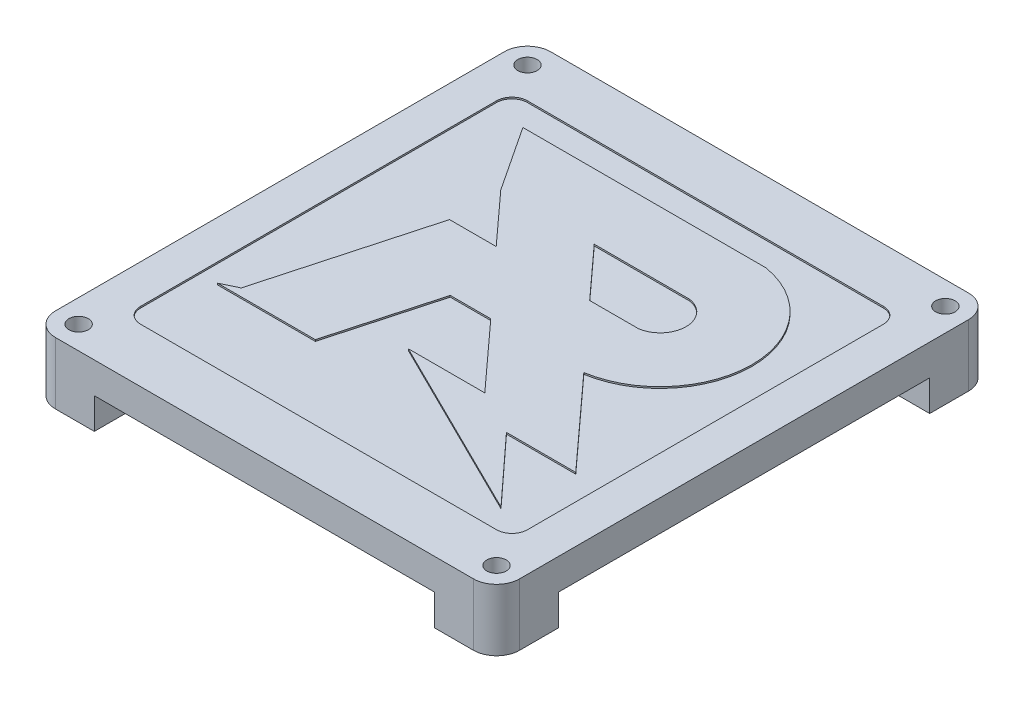
from build123d import *

# Parameters (mm, degrees)
EXTRUDE_1_DEPTH     = 4
EXTRUDE_2_DEPTH     = 4
SKETCH_3_R          = 1.25
CUT_EXTRUDE_1_DEPTH = 15
CUT_EXTRUDE_2_DEPTH = 0.2


with BuildPart() as part:
    # 草图1 → 凸台-拉伸1 (new body)
    with BuildSketch(Plane(origin=(0, 0, 0), x_dir=(1, 0, 0), z_dir=(0, 1, 0))):
        with BuildLine():
            Line((-27.00005461, -31.987363475), (27.00005461, -31.987363475))
            ThreePointArc((27.00005461, -31.987363475), (29.112398272, -31.112402082), (29.987359665, -29.00005842))
            Line((29.987359665, -29.00005842), (29.987359665, 29.00005842))
            ThreePointArc((29.987359665, 29.00005842), (29.112398272, 31.112402082), (27.00005461, 31.987363475))
            Line((27.00005461, 31.987363475), (-27.00005461, 31.987363475))
            ThreePointArc((-27.00005461, 31.987363475), (-29.112398272, 31.112402082), (-29.987359665, 29.00005842))
            Line((-29.987359665, 29.00005842), (-29.987359665, -29.00005842))
            ThreePointArc((-29.987359665, -29.00005842), (-29.112398272, -31.112402082), (-27.00005461, -31.987363475))
        make_face()
    extrude(amount=EXTRUDE_1_DEPTH)

    # 草图2 → 凸台-拉伸2 (add)
    with BuildSketch(Plane.XZ):
        with BuildLine():
            Line((21.987359665, 23.987363475), (29.987359665, 23.987363475))
            Line((29.987359665, 23.987363475), (29.987359665, 29.00005842))
            ThreePointArc((29.987359665, 29.00005842), (29.112398272, 31.112402082), (27.00005461, 31.987363475))
            Line((27.00005461, 31.987363475), (21.987359665, 31.987363475))
            Line((21.987359665, 31.987363475), (21.987359665, 23.987363475))
        make_face()
        with BuildLine():
            Line((27.00005461, -31.987363475), (21.987359665, -31.987363475))
            Line((21.987359665, -31.987363475), (21.987359665, -23.987363475))
            Line((21.987359665, -23.987363475), (29.987359665, -23.987363475))
            Line((29.987359665, -23.987363475), (29.987359665, -29.00005842))
            ThreePointArc((29.987359665, -29.00005842), (29.112398272, -31.112402082), (27.00005461, -31.987363475))
        make_face()
        with BuildLine():
            Line((-21.987359665, 23.987363475), (-21.987359665, 31.987363475))
            Line((-21.987359665, 31.987363475), (-27.00005461, 31.987363475))
            ThreePointArc((-27.00005461, 31.987363475), (-29.112398272, 31.112402082), (-29.987359665, 29.00005842))
            Line((-29.987359665, 29.00005842), (-29.987359665, 23.987363475))
            Line((-29.987359665, 23.987363475), (-21.987359665, 23.987363475))
        make_face()
        with BuildLine():
            Line((-29.987359665, -23.987363475), (-29.987359665, -29.00005842))
            ThreePointArc((-29.987359665, -29.00005842), (-29.112398272, -31.112402082), (-27.00005461, -31.987363475))
            Line((-27.00005461, -31.987363475), (-21.987359665, -31.987363475))
            Line((-21.987359665, -31.987363475), (-21.987359665, -23.987363475))
            Line((-21.987359665, -23.987363475), (-29.987359665, -23.987363475))
        make_face()
    extrude(amount=EXTRUDE_2_DEPTH)

    # 草图3 → 切除-拉伸1 (cut)
    with BuildSketch(Plane.XZ.offset(4)):
        with Locations((-27.00005461, 29.00005842)):
            Circle(SKETCH_3_R)
        with Locations((27.00005461, 29.00005842)):
            Circle(SKETCH_3_R)
        with Locations((27.00005461, -29.00005842)):
            Circle(SKETCH_3_R)
        with Locations((-27.00005461, -29.00005842)):
            Circle(SKETCH_3_R)
    extrude(amount=-CUT_EXTRUDE_1_DEPTH, mode=Mode.SUBTRACT)

    # 草图5 → 切除-拉伸2 (cut)
    with BuildSketch(Plane(origin=(0, 4, 0), x_dir=(1, 0, 0), z_dir=(0, 1, 0))):
        with BuildLine():
            Line((-23, 25), (23, 25))
            ThreePointArc((23, 25), (24.414213562, 24.414213562), (25, 23))
            Line((25, 23), (25, -23))
            ThreePointArc((25, -23), (24.414213562, -24.414213562), (23, -25))
            Line((23, -25), (-23, -25))
            ThreePointArc((-23, -25), (-24.414213562, -24.414213562), (-25, -23))
            Line((-25, -23), (-25, 23))
            ThreePointArc((-25, 23), (-24.414213562, 24.414213562), (-23, 25))
        make_face()
        with BuildLine():
            Line((-20.309132479, 21.7161472), (11.083615015, 21.7161472))
            ThreePointArc((11.083615015, 21.7161472), (21.032992317, 9.959590783), (11.052213822, -1.770319196))
            Line((11.052213822, -1.770319196), (21.701392553, -13.464868734))
            Line((21.701392553, -13.464868734), (12.747815073, -13.464868734))
            Line((12.747815073, -13.464868734), (20.738271333, -22.160710638))
            Line((20.738271333, -22.160710638), (20.674664, -22.129263034))
            Line((20.674664, -22.129263034), (20.610679736, -22.097629074))
            Line((20.610679736, -22.097629074), (-2.958144095, -10.445151208))
            Line((-2.958144095, -10.445151208), (6.929882372, -10.445151208))
            Line((6.929882372, -10.445151208), (-0.976260078, -1.765140225))
            Line((-0.976260078, -1.765140225), (-6.216100572, -1.765140225))
            Line((-6.216100572, -1.765140225), (-9.975490326, -15.423548609))
            Line((-9.975490326, -15.423548609), (-9.977986633, -15.432618054))
            Line((-9.977986633, -15.432618054), (-22.608758584, -15.432618054))
            Line((-22.608758584, -15.432618054), (-20.552621384, -14.439759274))
            Line((-20.552621384, -14.439759274), (-14.742658641, 6.668678272))
            Line((-14.742658641, 6.668678272), (-8.710796679, 6.668678272))
            Line((-8.710796679, 6.668678272), (-14.742658641, 13.290950565))
            Line((-14.742658641, 13.290950565), (-20.309132479, 21.7161472))
        make_face(mode=Mode.SUBTRACT)
        with BuildLine():
            Line((3.367574747, 6.668678272), (-2.642308815, 13.268518768))
            Line((-2.642308815, 13.268518768), (9.694238704, 13.268518768))
            ThreePointArc((9.694238704, 13.268518768), (12.526480913, 9.96859852), (9.694238704, 6.668678272))
            Line((9.694238704, 6.668678272), (3.367574747, 6.668678272))
        make_face()
    extrude(amount=-CUT_EXTRUDE_2_DEPTH, mode=Mode.SUBTRACT)


solid = part.part
